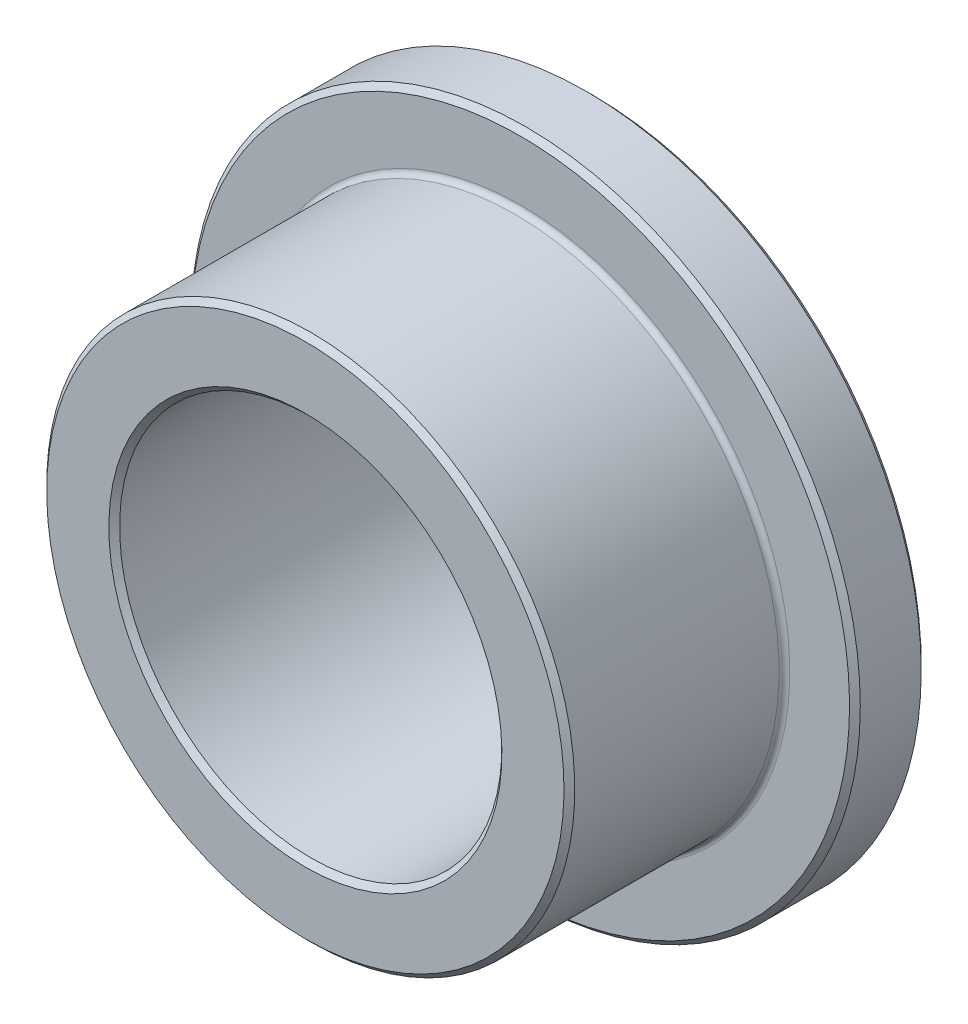
from build123d import *

# Parameters (mm, degrees)
CHAMFER1_SIZE = 0.1125
FILLET1_R     = 0.1125


with BuildPart() as part:
    # Sketch3 → Revolve1 (revolve)
    with BuildSketch(Plane(origin=(0, 0, 0), x_dir=(0, 0, -1), z_dir=(1, 0, 0))):
        Polygon((3, 7), (1.5, 7), (1.5, 5.525), (-3, 5.525), (-3, 4), (3, 4), align=None)
    revolve(axis=Axis((0, 0, -3), (0, 0, 1)))

    # Chamfer1
    chamfer1_edges = [part.edges().sort_by_distance(p)[0] for p in [
        (0, -4, 3),
        (0, -5.525, 3),
        (0, -7, -1.5),
        (0, -7, -3),
    ]]
    chamfer(chamfer1_edges, length=CHAMFER1_SIZE)

    # Fillet1
    fillet1_edges = [part.edges().sort_by_distance(p)[0] for p in [
        (0, -5.525, -1.5),
    ]]
    fillet(fillet1_edges, radius=FILLET1_R)


solid = part.part
